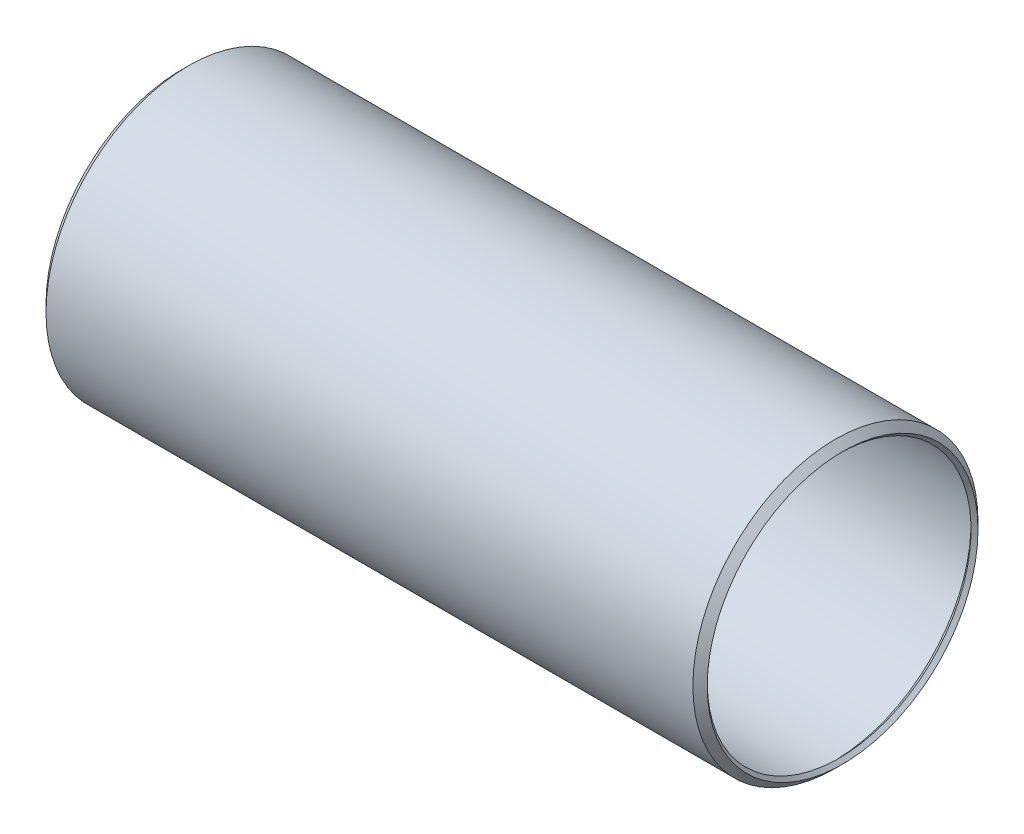
from build123d import *


with BuildPart() as part:
    # Sketch1 → Revolve1 (revolve)
    with BuildSketch(Plane.XY):
        Polygon((-113.778178441, 25.157578441), (-113.1316, 24.511), (-112.0648, 25.5778), (7.3914, 25.5778), (8.4582, 24.511), (9.104778441, 25.157578441), (7.770156881, 26.4922), (-112.443556881, 26.4922), align=None)
    revolve(axis=Axis((7.3914, 0, 0), (-1, 0, 0)))


solid = part.part
